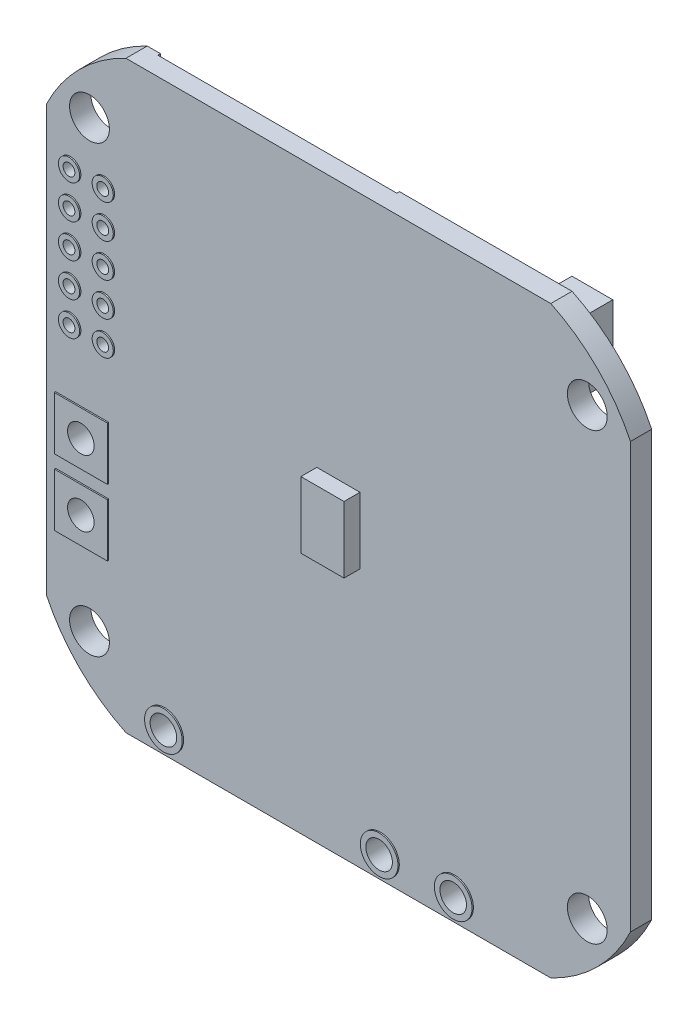
from build123d import *

# Parameters (mm, degrees)
SALIENTE_EXTRUIR1_DEPTH    = 0.8
CROQUIS2_R                 = 1.5
CORTAR_EXTRUIR1_DEPTH      = 32.153811966
CROQUIS3_W                 = 3.25
CROQUIS3_H                 = 5
SALIENTE_EXTRUIR2_DEPTH    = 1.2
CROQUIS4_R                 = 0.445
CORTAR_EXTRUIR2_DEPTH      = 32.238437861
CROQUIS5_R                 = 0.79739254
CROQUIS5_R_2               = 0.445
CROQUIS5_W                 = 4
CROQUIS5_H                 = 4
SALIENTE_EXTRUIR3_DEPTH    = 0.9
CORTAR_EXTRUIR3_DEPTH      = 32.247559905
CORTAR_EXTRUIR3_DEPTH_BACK = 32.247559905
CROQUIS6_R                 = 1
CROQUIS7_R                 = 1
CORTAR_EXTRUIR4_DEPTH      = 10
CROQUIS8_W                 = 3
CROQUIS8_H                 = 2.5
SALIENTE_EXTRUIR4_DEPTH    = 1.2
CROQUIS9_R                 = 0.75
SALIENTE_EXTRUIR5_DEPTH    = 0.8
CROQUIS10_W                = 5
CROQUIS10_H                = 5
SALIENTE_EXTRUIR6_DEPTH    = 0.9
SALIENTE_EXTRUIR7_START    = 0.1
CROQUIS11_R                = 1
SALIENTE_EXTRUIR7_DEPTH    = 0.1
SALIENTE_EXTRUIR8_DEPTH    = 0.75
CROQUIS13_W                = 3.080395022
CROQUIS13_H                = 5.233680862
SALIENTE_EXTRUIR9_DEPTH    = 2.65
CROQUIS14_W                = 3.82
CROQUIS14_H                = 3.82
SALIENTE_EXTRUIR10_DEPTH   = 3
CROQUIS30_R                = 1.419915385
CROQUIS30_R_2              = 1
SALIENTE_EXTRUIR17_DEPTH   = 0.1
CROQUIS29_W                = 3.5
CROQUIS29_H                = 1.5
SALIENTE_EXTRUIR16_DEPTH   = 0.5
CHAFL_N1_SIZE              = 1
CROQUIS31_W                = 18
CROQUIS31_H                = 19.35
CORTAR_EXTRUIR5_DEPTH      = 0.2


with BuildPart() as part:
    # Croquis1 → Saliente-Extruir1 (new, symmetric)
    with BuildSketch(Plane.XY):
        with BuildLine():
            Line((-22, 16), (-22, -16))
            ThreePointArc((-22, -16), (-19.513773424, -19.513773424), (-16, -22))
            Line((-16, -22), (16, -22))
            ThreePointArc((16, -22), (19.513773424, -19.513773424), (22, -16))
            Line((22, -16), (22, 16))
            ThreePointArc((22, 16), (19.513773424, 19.513773424), (16, 22))
            Line((16, 22), (-16, 22))
            ThreePointArc((-16, 22), (-19.513773424, 19.513773424), (-22, 16))
        make_face()
    extrude(amount=SALIENTE_EXTRUIR1_DEPTH, both=True)

    # Croquis2 → Cortar-Extruir1 (cut, through all)
    with BuildSketch(Plane.XY.offset(0.8)):
        with Locations((-18.75, 16.75)):
            Circle(CROQUIS2_R)
        with Locations((18.75, 16.75)):
            Circle(CROQUIS2_R)
        with Locations((18.75, -16.75)):
            Circle(CROQUIS2_R)
        with Locations((-18.75, -16.75)):
            Circle(CROQUIS2_R)
    extrude(amount=-CORTAR_EXTRUIR1_DEPTH, mode=Mode.SUBTRACT)

    # Croquis3 → Saliente-Extruir2 (add)
    with BuildSketch(Plane.XY.offset(0.8)):
        Rectangle(CROQUIS3_W, CROQUIS3_H)
    extrude(amount=SALIENTE_EXTRUIR2_DEPTH)

    # Croquis4 → Cortar-Extruir2 (cut, through all)
    with BuildSketch(Plane(origin=(0, 0, -0.8), x_dir=(-1, 0, 0), z_dir=(0, 0, -1))):
        with Locations((17.653, 12.7)):
            Circle(CROQUIS4_R)
        with Locations((20.193, 12.7)):
            Circle(CROQUIS4_R)
        with Locations((20.193, 10.16)):
            Circle(CROQUIS4_R)
        with Locations((20.193, 7.62)):
            Circle(CROQUIS4_R)
        with Locations((20.193, 5.08)):
            Circle(CROQUIS4_R)
        with Locations((20.193, 2.54)):
            Circle(CROQUIS4_R)
        with Locations((17.653, 10.16)):
            Circle(CROQUIS4_R)
        with Locations((17.653, 7.62)):
            Circle(CROQUIS4_R)
        with Locations((17.653, 5.08)):
            Circle(CROQUIS4_R)
        with Locations((17.653, 2.54)):
            Circle(CROQUIS4_R)
    extrude(amount=-CORTAR_EXTRUIR2_DEPTH, mode=Mode.SUBTRACT)

    # Croquis5 → Saliente-Extruir3 (add, symmetric)
    # profile 1 of 12: a face of its own
    with BuildSketch(Plane.XY):
        with Locations((-17.653, 2.54)):
            Circle(CROQUIS5_R)
        with Locations((-17.653, 2.54)):
            Circle(CROQUIS5_R_2, mode=Mode.SUBTRACT)
    # profile 2 of 12: a face of its own
    with BuildSketch(Plane.XY):
        with Locations((-20.193, 2.54)):
            Circle(CROQUIS5_R)
        with Locations((-20.193, 2.54)):
            Circle(CROQUIS5_R_2, mode=Mode.SUBTRACT)
    # profile 3 of 12: a face of its own
    with BuildSketch(Plane.XY):
        with Locations((-20.193, 5.08)):
            Circle(CROQUIS5_R)
        with Locations((-20.193, 5.08)):
            Circle(CROQUIS5_R_2, mode=Mode.SUBTRACT)
    # profile 4 of 12: a face of its own
    with BuildSketch(Plane.XY):
        with Locations((-17.653, 5.08)):
            Circle(CROQUIS5_R)
        with Locations((-17.653, 5.08)):
            Circle(CROQUIS5_R_2, mode=Mode.SUBTRACT)
    # profile 5 of 12: a face of its own
    with BuildSketch(Plane.XY):
        with Locations((-17.653, 7.62)):
            Circle(CROQUIS5_R)
        with Locations((-17.653, 7.62)):
            Circle(CROQUIS5_R_2, mode=Mode.SUBTRACT)
    # profile 6 of 12: a face of its own
    with BuildSketch(Plane.XY):
        with Locations((-17.653, 10.16)):
            Circle(CROQUIS5_R)
        with Locations((-17.653, 10.16)):
            Circle(CROQUIS5_R_2, mode=Mode.SUBTRACT)
    # profile 7 of 12: a face of its own
    with BuildSketch(Plane.XY):
        with Locations((-20.193, 7.62)):
            Circle(CROQUIS5_R)
        with Locations((-20.193, 7.62)):
            Circle(CROQUIS5_R_2, mode=Mode.SUBTRACT)
    # profile 8 of 12: a face of its own
    with BuildSketch(Plane.XY):
        with Locations((-20.193, 10.16)):
            Circle(CROQUIS5_R)
        with Locations((-20.193, 10.16)):
            Circle(CROQUIS5_R_2, mode=Mode.SUBTRACT)
    # profile 9 of 12: a face of its own
    with BuildSketch(Plane.XY):
        with Locations((-17.653, 12.7)):
            Circle(CROQUIS5_R)
        with Locations((-17.653, 12.7)):
            Circle(CROQUIS5_R_2, mode=Mode.SUBTRACT)
    # profile 10 of 12: a face of its own
    with BuildSketch(Plane.XY):
        with Locations((-20.193, 12.7)):
            Circle(CROQUIS5_R)
        with Locations((-20.193, 12.7)):
            Circle(CROQUIS5_R_2, mode=Mode.SUBTRACT)
    # profile 11 of 12: a face of its own
    with BuildSketch(Plane.XY):
        with Locations((-19.3, -4.4)):
            Rectangle(CROQUIS5_W, CROQUIS5_H)
    # profile 12 of 12: a face of its own
    with BuildSketch(Plane.XY):
        with Locations((-19.3, -9.4)):
            Rectangle(CROQUIS5_W, CROQUIS5_H)
    extrude(amount=SALIENTE_EXTRUIR3_DEPTH, both=True)

    # Croquis6 → Cortar-Extruir3 (cut, two sides: drawn at the far end of the back side and taken through both)
    with BuildSketch(Plane(origin=(0, 0, -0.9), x_dir=(-1, 0, 0), z_dir=(0, 0, -1)).offset(-CORTAR_EXTRUIR3_DEPTH_BACK)):
        with Locations((19.3, -4.4)):
            Circle(CROQUIS6_R)
        with Locations((19.3, -9.4)):
            Circle(CROQUIS6_R)
    extrude(amount=CORTAR_EXTRUIR3_DEPTH + CORTAR_EXTRUIR3_DEPTH_BACK, mode=Mode.SUBTRACT)

    # Croquis7 → Cortar-Extruir4 (cut)
    with BuildSketch(Plane(origin=(0, 0, -0.8), x_dir=(-1, 0, 0), z_dir=(0, 0, -1))):
        with Locations((-8.75, -20.32)):
            Circle(CROQUIS7_R)
        with Locations((-3.17, -20.32)):
            Circle(CROQUIS7_R)
        with Locations((13.08, -20.32)):
            Circle(CROQUIS7_R)
    extrude(amount=-CORTAR_EXTRUIR4_DEPTH, mode=Mode.SUBTRACT)

    # Croquis8 → Saliente-Extruir4 (add)
    with BuildSketch(Plane(origin=(0, 0, -0.8), x_dir=(-1, 0, 0), z_dir=(0, 0, -1))):
        with Locations((-19, 11.7)):
            Rectangle(CROQUIS8_W, CROQUIS8_H)
        with Locations((-19, 8.7)):
            Rectangle(CROQUIS8_W, CROQUIS8_H)
    extrude(amount=SALIENTE_EXTRUIR4_DEPTH)

    # Croquis9 → Saliente-Extruir5 (add)
    with BuildSketch(Plane(origin=(0, 0, -2), x_dir=(-1, 0, 0), z_dir=(0, 0, -1))):
        with Locations((-19, 11.7)):
            Circle(CROQUIS9_R)
        with Locations((-19, 8.7)):
            Circle(CROQUIS9_R)
    extrude(amount=SALIENTE_EXTRUIR5_DEPTH)

    # Croquis10 → Saliente-Extruir6 (add)
    with BuildSketch(Plane(origin=(0, 0, -0.8), x_dir=(-1, 0, 0), z_dir=(0, 0, -1))):
        with Locations((-13.5, -16.75)):
            Rectangle(CROQUIS10_W, CROQUIS10_H)
        with Locations((13.75, -14.7)):
            Rectangle(CROQUIS10_W, CROQUIS10_H)
        with Locations((8.387686328, -16.75)):
            Rectangle(CROQUIS10_W, CROQUIS10_H)
        with Locations((2.934297752, -16.75)):
            Rectangle(CROQUIS10_W, CROQUIS10_H)
        with Locations((-2.448267596, -14.7)):
            Rectangle(CROQUIS10_W, CROQUIS10_H)
        with Locations((-8.043302629, -14.7)):
            Rectangle(CROQUIS10_W, CROQUIS10_H)
    extrude(amount=SALIENTE_EXTRUIR6_DEPTH)

    # Croquis11 → Saliente-Extruir7 (add)
    # profile 1 of 3: a face of its own
    with BuildSketch(Plane(origin=(0, 0, -0.8), x_dir=(-1, 0, 0), z_dir=(0, 0, -1)).offset(SALIENTE_EXTRUIR7_START)):
        Polygon((-13.652894244, -19.522521794), (-10.45933095, -19.522521794), (-9.812366284, -18.875557129), (-7.528981863, -18.875557129), (-7.147566948, -19.256972043), (-7.147566948, -21.343674777), (-7.528981863, -21.725089692), (-13.830102074, -21.725089692), (-14.141358707, -21.413833058), (-14.141358707, -20.010986258), align=None)
        with Locations((-8.75, -20.32)):
            Circle(CROQUIS11_R, mode=Mode.SUBTRACT)
    # profile 2 of 3: a face of its own
    with BuildSketch(Plane(origin=(0, 0, -0.8), x_dir=(-1, 0, 0), z_dir=(0, 0, -1)).offset(SALIENTE_EXTRUIR7_START)):
        Polygon((8.172318821, -19.522521794), (11.198277852, -19.522521794), (12.022450347, -18.698349299), (14.296231203, -18.698349299), (14.77845979, -19.180577887), (14.77845979, -21.242861104), (14.296231203, -21.725089692), (7.995110992, -21.725089692), (7.683854358, -21.413833058), (7.683854358, -20.010986258), align=None)
        with Locations((13.08, -20.32)):
            Circle(CROQUIS11_R, mode=Mode.SUBTRACT)
    # profile 3 of 3: a face of its own
    with BuildSketch(Plane(origin=(0, 0, -0.8), x_dir=(-1, 0, 0), z_dir=(0, 0, -1)).offset(SALIENTE_EXTRUIR7_START)):
        Polygon((2.263089361, -20.010986258), (1.774624897, -19.522521794), (-1.418938397, -19.522521794), (-2.065903062, -18.875557129), (-4.349287484, -18.875557129), (-4.730702399, -19.256972043), (-4.730702399, -21.343674777), (-4.349287484, -21.725089692), (1.951832727, -21.725089692), (2.263089361, -21.413833058), align=None)
        with Locations((-3.17, -20.32)):
            Circle(CROQUIS11_R, mode=Mode.SUBTRACT)
    extrude(amount=-SALIENTE_EXTRUIR7_DEPTH)

    # Croquis12 → Saliente-Extruir8 (add)
    with BuildSketch(Plane(origin=(0, 0, -0.8), x_dir=(-1, 0, 0), z_dir=(0, 0, -1))):
        Polygon((-19.575208836, -2.789767852), (-13.48447481, -8.880501877), (-7.393740785, -2.789767852), (-13.48447481, 3.300966173), align=None)
    extrude(amount=SALIENTE_EXTRUIR8_DEPTH)

    # Croquis13 → Saliente-Extruir9 (add)
    with BuildSketch(Plane(origin=(0, 0, -0.8), x_dir=(-1, 0, 0), z_dir=(0, 0, -1))):
        with Locations((-14.88146784, 17.715085573)):
            Rectangle(CROQUIS13_W, CROQUIS13_H)
    extrude(amount=SALIENTE_EXTRUIR9_DEPTH)

    # Croquis14 → Saliente-Extruir10 (add)
    with BuildSketch(Plane(origin=(0, 0, -0.8), x_dir=(-1, 0, 0), z_dir=(0, 0, -1))):
        with Locations((-10.141101814, 15.498369959)):
            Rectangle(CROQUIS14_W, CROQUIS14_H)
    extrude(amount=SALIENTE_EXTRUIR10_DEPTH)

    # Croquis30 → Saliente-Extruir17 (add)
    # profile 1 of 3: a face of its own
    with BuildSketch(Plane.XY.offset(0.8)):
        with Locations((-13.08, -20.32)):
            Circle(CROQUIS30_R)
        with Locations(Location((-13.08, -20.32, 0), (0, 0, 180))):
            Circle(CROQUIS30_R_2, mode=Mode.SUBTRACT)
    # profile 2 of 3: a face of its own
    with BuildSketch(Plane.XY.offset(0.8)):
        with Locations((8.75, -20.32)):
            Circle(CROQUIS30_R)
        with Locations(Location((8.75, -20.32, 0), (0, 0, 180))):
            Circle(CROQUIS30_R_2, mode=Mode.SUBTRACT)
    # profile 3 of 3: a face of its own
    with BuildSketch(Plane.XY.offset(0.8)):
        with Locations((3.17, -20.32)):
            Circle(CROQUIS30_R)
        with Locations(Location((3.17, -20.32, 0), (0, 0, 180))):
            Circle(CROQUIS30_R_2, mode=Mode.SUBTRACT)
    extrude(amount=SALIENTE_EXTRUIR17_DEPTH)

    # Croquis29 → Saliente-Extruir16 (add)
    with BuildSketch(Plane(origin=(0, 0, -0.8), x_dir=(-1, 0, 0), z_dir=(0, 0, -1))):
        with Locations((12.25, 0.75)):
            Rectangle(CROQUIS29_W, CROQUIS29_H)
        with Locations((12.25, -1.4)):
            Rectangle(CROQUIS29_W, CROQUIS29_H)
        with Locations((4.5, 0.75)):
            Rectangle(CROQUIS29_W, CROQUIS29_H)
    extrude(amount=SALIENTE_EXTRUIR16_DEPTH)

    # Chaflán1
    chafl_n1_edges = [part.edges().sort_by_distance(p)[0] for p in [
        (12.051101814, 17.408369959, -2.3),
        (12.051101814, 13.588369959, -2.3),
        (8.231101814, 13.588369959, -2.3),
        (8.231101814, 17.408369959, -2.3),
    ]]
    chamfer(chafl_n1_edges, length=CHAFL_N1_SIZE)

    # Croquis31 → Cortar-Extruir5 (cut)
    with BuildSketch(Plane(origin=(0, 0, -0.8), x_dir=(-1, 0, 0), z_dir=(0, 0, -1))):
        with Locations((6, 12.325)):
            Rectangle(CROQUIS31_W, CROQUIS31_H)
    extrude(amount=-CORTAR_EXTRUIR5_DEPTH, mode=Mode.SUBTRACT)


solid = part.part
